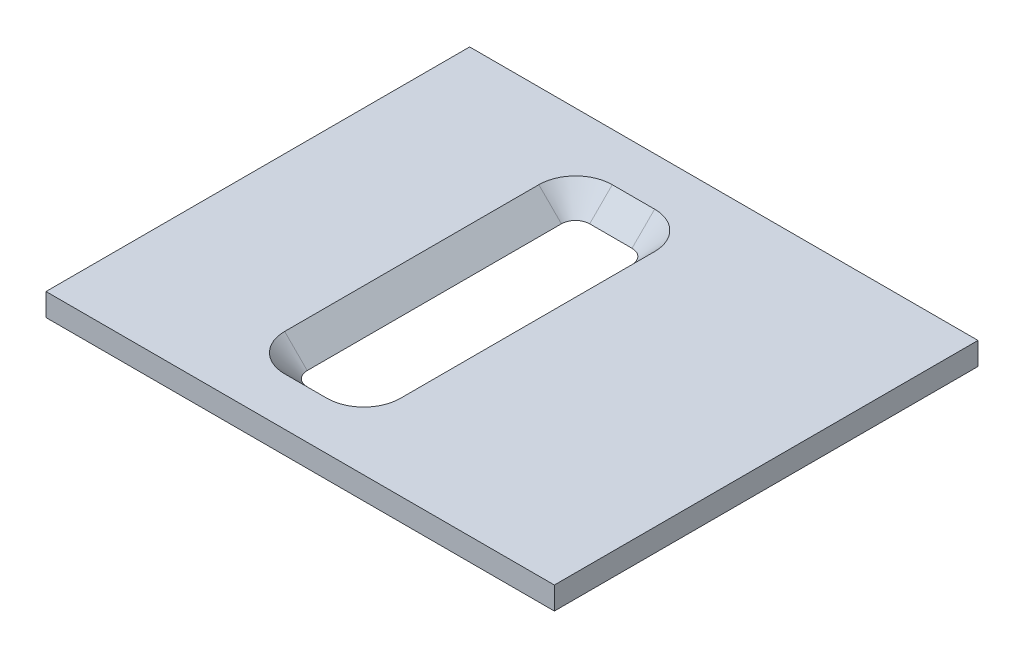
from build123d import *

# Parameters (mm, degrees)
SKETCH2_W           = 36
SKETCH2_H           = 30
BOSS_EXTRUDE1_DEPTH = 1.6002
CUT_EXTRUDE4_DEPTH  = 2.6002
CUT_EXTRUDE4_TAPER  = -45


with BuildPart() as part:
    # Sketch2 → Boss-Extrude1 (new body)
    with BuildSketch(Plane(origin=(0, 0, 0), x_dir=(1, 0, 0), z_dir=(0, 1, 0))):
        with Locations((3, 0)):
            Rectangle(SKETCH2_W, SKETCH2_H)
    extrude(amount=BOSS_EXTRUDE1_DEPTH)

    # Sketch4 → Cut-Extrude4 (cut, through all)
    with BuildSketch(Plane(origin=(0, 0, 0), x_dir=(1, 0, 0), z_dir=(0, 1, 0))):
        with BuildLine():
            ThreePointArc((1.5, -10), (2.207106781, -9.707106781), (2.5, -9))
            Line((2.5, -9), (2.5, 9))
            ThreePointArc((2.5, 9), (2.207106781, 9.707106781), (1.5, 10))
            Line((1.5, 10), (-1.5, 10))
            ThreePointArc((-1.5, 10), (-2.207106781, 9.707106781), (-2.5, 9))
            Line((-2.5, 9), (-2.5, -9))
            ThreePointArc((-2.5, -9), (-2.207106781, -9.707106781), (-1.5, -10))
            Line((-1.5, -10), (1.5, -10))
        make_face()
    extrude(amount=CUT_EXTRUDE4_DEPTH, taper=CUT_EXTRUDE4_TAPER, mode=Mode.SUBTRACT)


solid = part.part
